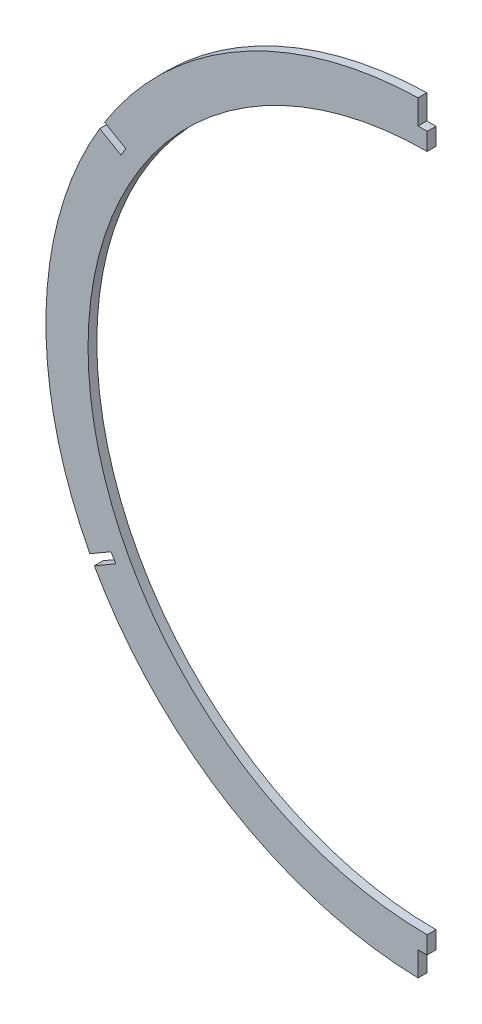
from build123d import *

# Parameters (mm, degrees)
SKETCH2_R           = 137.922
SKETCH2_R_2         = 122.682
BOSS_EXTRUDE2_DEPTH = 1.5875
SKETCH3_W           = 290.977734258
SKETCH3_H           = 504.828840158
CUT_EXTRUDE1_DEPTH  = 138.922
CUT_EXTRUDE2_DEPTH  = 4.175


with BuildPart() as part:
    # Sketch2 → Boss-Extrude2 (new body, symmetric)
    with BuildSketch(Plane(origin=(248.273568551, -245.01347209, 0), x_dir=(0, -1, 0), z_dir=(0, 0, -1))):
        with Locations((-257.71347209, 248.273568551)):
            Circle(SKETCH2_R)
        with Locations((-257.71347209, 248.273568551)):
            Circle(SKETCH2_R_2, mode=Mode.SUBTRACT)
    extrude(amount=BOSS_EXTRUDE2_DEPTH, both=True)

    # Sketch3 → Cut-Extrude1 (cut, through all)
    with BuildSketch(Plane(origin=(0, 0, 0), x_dir=(0, 0, -1), z_dir=(1, 0, 0))):
        with Locations((4.206907001, 10.947122083)):
            Rectangle(SKETCH3_W, SKETCH3_H)
    extrude(amount=CUT_EXTRUDE1_DEPTH, mode=Mode.SUBTRACT)

    # Sketch5 → Cut-Extrude2 (cut, through all)
    with BuildSketch(Plane.XY.offset(1.5875)):
        with BuildLine():
            Line((-3.302, 150.582467631), (-3.302, 141.732))
            Line((-3.302, 141.732), (0, 141.732))
            Line((0, 141.732), (0, 150.622))
            ThreePointArc((0, 150.622), (-1.651118319, 150.612116554), (-3.302, 150.582467631))
        make_face()
        with BuildLine():
            Line((-109.043255392, 81.788598611), (-116.699944513, 86.209190137))
            ThreePointArc((-116.699944513, 86.209190137), (-117.591747875, 84.773982239), (-118.465901574, 83.327956562))
            Line((-118.465901574, 83.327956562), (-110.732355392, 78.862991592))
            Line((-110.732355392, 78.862991592), (-109.043255392, 81.788598611))
        make_face()
        with BuildLine():
            Line((-114.354109205, -47.189929975), (-122.010798327, -51.610521501))
            ThreePointArc((-122.010798327, -51.610521501), (-121.213773508, -53.100449816), (-120.398555388, -54.580501964))
            Line((-120.398555388, -54.580501964), (-112.665009205, -50.115536994))
            Line((-112.665009205, -50.115536994), (-114.354109205, -47.189929975))
        make_face()
        with BuildLine():
            Line((-3.302, -116.332), (-3.302, -125.182467631))
            ThreePointArc((-3.302, -125.182467631), (-1.651118319, -125.212116554), (0, -125.222))
            Line((0, -125.222), (0, -116.332))
            Line((0, -116.332), (-3.302, -116.332))
        make_face()
    extrude(amount=-CUT_EXTRUDE2_DEPTH, mode=Mode.SUBTRACT)


solid = part.part
